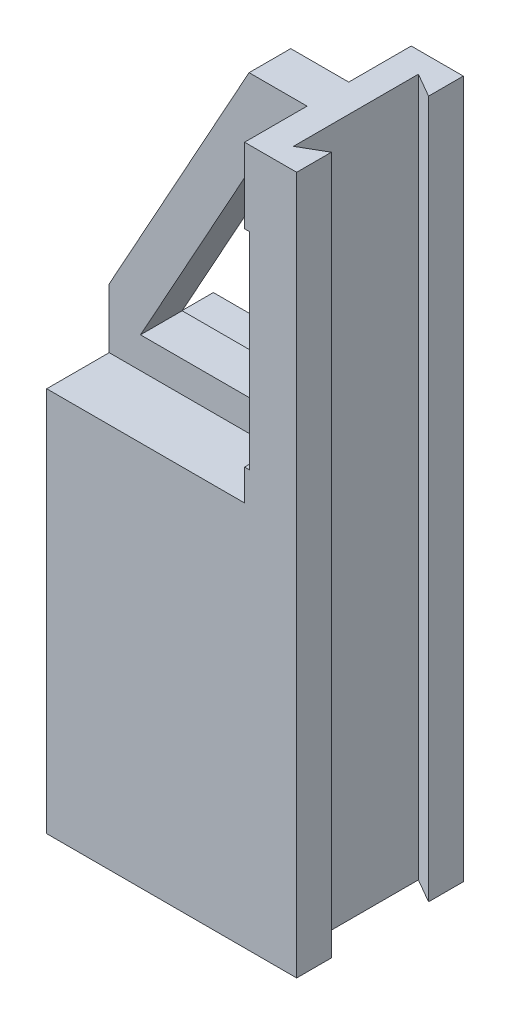
from build123d import *

# Parameters (mm, degrees)
EXTRUDE_1_DEPTH     = 80
SKETCH_2_W          = 95
SKETCH_2_H          = 30
CUT_EXTRUDE_1_DEPTH = 150
CUT_EXTRUDE_2_DEPTH = 336


with BuildPart() as part:
    # Эскиз1 → Бобышка-Вытянуть1 (new body)
    with BuildSketch(Plane.XY):
        Polygon((0, 0), (120, 0), (120, 335), (67.160475454, 335), (0, 213.59536065), align=None)
        Polygon((15.034284713, 199.934070047), (69.825157074, 298.978426921), (97.39949173, 298.978426921), (97.39949173, 199.934070047), align=None, mode=Mode.SUBTRACT)
    extrude(amount=EXTRUDE_1_DEPTH)

    # Эскиз2 → Вырез-Вытянуть1 (cut)
    with BuildSketch(Plane(origin=(0, 335, 0), x_dir=(1, 0, 0), z_dir=(0, 1, 0))):
        with Locations((47.5, -15)):
            Rectangle(SKETCH_2_W, SKETCH_2_H)
        with Locations((47.5, -65)):
            Rectangle(SKETCH_2_W, SKETCH_2_H)
    extrude(amount=-CUT_EXTRUDE_1_DEPTH, mode=Mode.SUBTRACT)

    # Эскиз3 → Вырез-Вытянуть2 (cut, through all)
    with BuildSketch(Plane(origin=(0, 335, 0), x_dir=(1, 0, 0), z_dir=(0, 1, 0))):
        Polygon((108.441945131, -10), (108.441945131, -70), (120, -63.32695391), (120, -16.67304609), align=None)
    extrude(amount=-CUT_EXTRUDE_2_DEPTH, mode=Mode.SUBTRACT)


solid = part.part
